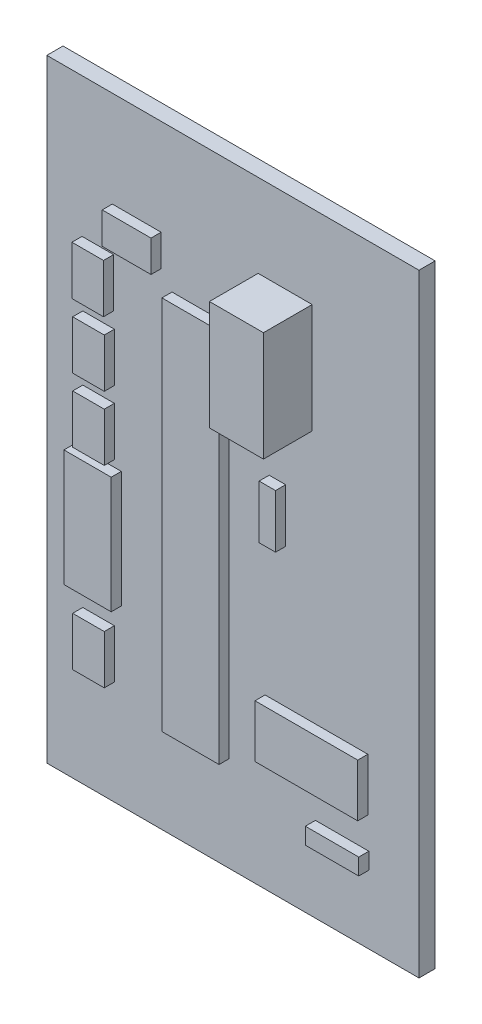
from build123d import *

# Parameters (mm, degrees)
SKETCH1_W                              = 36.81
SKETCH1_H                              = 60.63
BOARD_DEPTH                            = 1.6
SKETCH2_W                              = 4.826
SKETCH2_H                              = 3.1242
C025_030X050_1_DEPTH                   = 1
SKETCH3_W                              = 3.1242
SKETCH3_H                              = 4.826
C025_030X050_2_DEPTH                   = 1
SKETCH4_W                              = 3.1242
SKETCH4_H                              = 4.826
C025_030X050_3_DEPTH                   = 1
SKETCH5_W                              = 3.1242
SKETCH5_H                              = 4.826
C025_030X050_4_DEPTH                   = 1
SKETCH6_W                              = 3.1242
SKETCH6_H                              = 4.826
C025_030X050_5_DEPTH                   = 1
SKETCH7_W                              = 10.16
SKETCH7_H                              = 5.207
AB9V_1_DEPTH                           = 1
SKETCH8_W                              = 5.6515
SKETCH8_H                              = 37.1475
DIL28_1_DEPTH                          = 1
SKETCH9_W                              = 5.7024
SKETCH9_H                              = 5.4564
RGBLED5050_1_DEPTH                     = 1
SKETCH10_W                             = 5.345
SKETCH10_H                             = 10.83
TO254P482X997X1968_3P_4_820000_1_DEPTH = 4.82
SKETCH11_W                             = 1.6256
SKETCH11_H                             = 5.2832
AXIAL_0_3_1_DEPTH                      = 1
SKETCH12_W                             = 5.2832
SKETCH12_H                             = 1.6256
AXIAL_0_3_2_DEPTH                      = 1
SKETCH13_W                             = 4.1275
SKETCH13_H                             = 11.7475
EG1218_1_DEPTH                         = 1
SKETCH14_W                             = 7.9
SKETCH14_H                             = 3.8
TACT_PANA_EVQ_1_DEPTH                  = 1
SKETCH15_W                             = 4.6736
SKETCH15_H                             = 11.5316
HC49US_1_DEPTH                         = 1


with BuildPart() as part:
    # Sketch1 → BOARD (new body)
    with BuildSketch(Plane.XY):
        with Locations((18.405, 30.315)):
            Rectangle(SKETCH1_W, SKETCH1_H)
    extrude(amount=BOARD_DEPTH)


with BuildPart() as body_2:
    # Sketch2 → C025-030X050-1 (new body)
    with BuildSketch(Plane.XY.offset(1.6)):
        with Locations((8.89, 49.5681)):
            Rectangle(SKETCH2_W, SKETCH2_H)
    extrude(amount=C025_030X050_1_DEPTH)


with BuildPart() as body_3:
    # Sketch3 → C025-030X050-2 (new body)
    with BuildSketch(Plane.XY.offset(1.6)):
        with Locations((5.0419, 44.45)):
            Rectangle(SKETCH3_W, SKETCH3_H)
    extrude(amount=C025_030X050_2_DEPTH)


with BuildPart() as body_4:
    # Sketch4 → C025-030X050-3 (new body)
    with BuildSketch(Plane.XY.offset(1.6)):
        with Locations((5.1181, 38.1)):
            Rectangle(SKETCH4_W, SKETCH4_H)
    extrude(amount=C025_030X050_3_DEPTH)


with BuildPart() as body_5:
    # Sketch5 → C025-030X050-4 (new body)
    with BuildSketch(Plane.XY.offset(1.6)):
        with Locations((5.1181, 31.75)):
            Rectangle(SKETCH5_W, SKETCH5_H)
    extrude(amount=C025_030X050_4_DEPTH)


with BuildPart() as body_6:
    # Sketch6 → C025-030X050-5 (new body)
    with BuildSketch(Plane.XY.offset(1.6)):
        with Locations((5.1181, 12.7)):
            Rectangle(SKETCH6_W, SKETCH6_H)
    extrude(amount=C025_030X050_5_DEPTH)


with BuildPart() as body_7:
    # Sketch7 → AB9V-1 (new body)
    with BuildSketch(Plane.XY.offset(1.6)):
        with Locations((26.67, 14.0335)):
            Rectangle(SKETCH7_W, SKETCH7_H)
    extrude(amount=AB9V_1_DEPTH)


with BuildPart() as body_8:
    # Sketch8 → DIL28-1 (new body)
    with BuildSketch(Plane.XY.offset(1.6)):
        with Locations((15.20825, 27.97175)):
            Rectangle(SKETCH8_W, SKETCH8_H)
    extrude(amount=DIL28_1_DEPTH)


with BuildPart() as body_9:
    # Sketch9 → RGBLED5050-1 (new body)
    with BuildSketch(Plane.XY):
        with Locations((28.9223, 32.8553)):
            Rectangle(SKETCH9_W, SKETCH9_H)
    extrude(amount=-RGBLED5050_1_DEPTH)


with BuildPart() as body_10:
    # Sketch10 → TO254P482X997X1968-3P_4.820000-1 (new body)
    with BuildSketch(Plane.XY.offset(1.6)):
        with Locations((23.5725, 46.99)):
            Rectangle(SKETCH10_W, SKETCH10_H)
    extrude(amount=TO254P482X997X1968_3P_4_820000_1_DEPTH)


with BuildPart() as body_11:
    # Sketch11 → AXIAL-0_3-1 (new body)
    with BuildSketch(Plane.XY.offset(1.6)):
        with Locations((22.8092, 33.02)):
            Rectangle(SKETCH11_W, SKETCH11_H)
    extrude(amount=AXIAL_0_3_1_DEPTH)


with BuildPart() as body_12:
    # Sketch12 → AXIAL-0_3-2 (new body)
    with BuildSketch(Plane.XY.offset(1.6)):
        with Locations((29.21, 7.5692)):
            Rectangle(SKETCH12_W, SKETCH12_H)
    extrude(amount=AXIAL_0_3_2_DEPTH)


with BuildPart() as body_13:
    # Sketch13 → EG1218-1 (new body)
    with BuildSketch(Plane.XY):
        with Locations((29.24175, 48.22825)):
            Rectangle(SKETCH13_W, SKETCH13_H)
    extrude(amount=-EG1218_1_DEPTH)


with BuildPart() as body_14:
    # Sketch14 → TACT_PANA-EVQ-1 (new body)
    with BuildSketch(Plane.XY):
        with Locations((29.21, 20.32)):
            Rectangle(SKETCH14_W, SKETCH14_H)
    extrude(amount=-TACT_PANA_EVQ_1_DEPTH)


with BuildPart() as body_15:
    # Sketch15 → HC49US-1 (new body)
    with BuildSketch(Plane.XY.offset(1.6)):
        with Locations((5.0292, 22.9108)):
            Rectangle(SKETCH15_W, SKETCH15_H)
    extrude(amount=HC49US_1_DEPTH)


solid = Compound([part.part, body_2.part, body_3.part, body_4.part, body_5.part, body_6.part, body_7.part, body_8.part, body_9.part, body_10.part, body_11.part, body_12.part, body_13.part, body_14.part, body_15.part])
